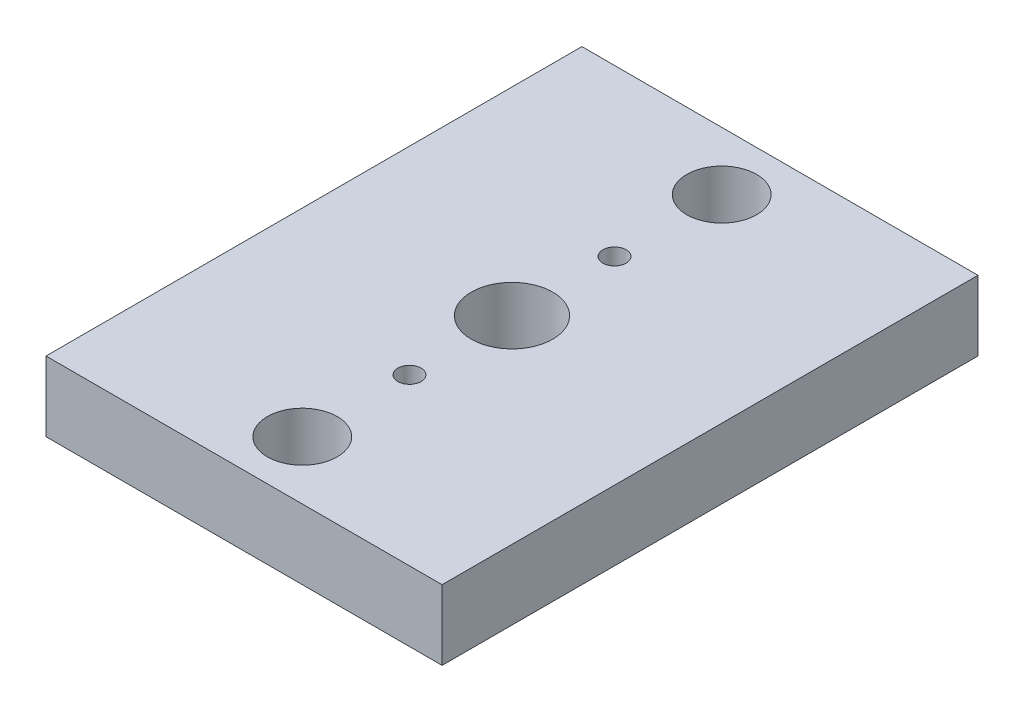
from build123d import *

# Parameters (mm, degrees)
SKETCH1_W           = 17
SKETCH1_H           = 23
BOSS_EXTRUDE1_DEPTH = 3
SKETCH2_R           = 1.5
SKETCH2_R_2         = 0.5
CUT_EXTRUDE1_DEPTH  = 4
SKETCH3_R           = 1.75
CUT_EXTRUDE2_DEPTH  = 4


with BuildPart() as part:
    # Sketch1 → Boss-Extrude1 (new body)
    with BuildSketch(Plane(origin=(0, 0, 0), x_dir=(1, 0, 0), z_dir=(0, 1, 0))):
        Rectangle(SKETCH1_W, SKETCH1_H)
    extrude(amount=BOSS_EXTRUDE1_DEPTH)

    # Sketch2 → Cut-Extrude1 (cut, through all)
    with BuildSketch(Plane(origin=(0, 3, 0), x_dir=(1, 0, 0), z_dir=(0, 1, 0))):
        with Locations((0, 9)):
            Circle(SKETCH2_R)
        with Locations((0, 4.4)):
            Circle(SKETCH2_R_2)
        with Locations((0, -4.4)):
            Circle(SKETCH2_R_2)
        with Locations((0, -9)):
            Circle(SKETCH2_R)
    extrude(amount=-CUT_EXTRUDE1_DEPTH, mode=Mode.SUBTRACT)

    # Sketch3 → Cut-Extrude2 (cut, through all)
    with BuildSketch(Plane(origin=(0, 3, 0), x_dir=(1, 0, 0), z_dir=(0, 1, 0))):
        Circle(SKETCH3_R)
    extrude(amount=-CUT_EXTRUDE2_DEPTH, mode=Mode.SUBTRACT)


solid = part.part
